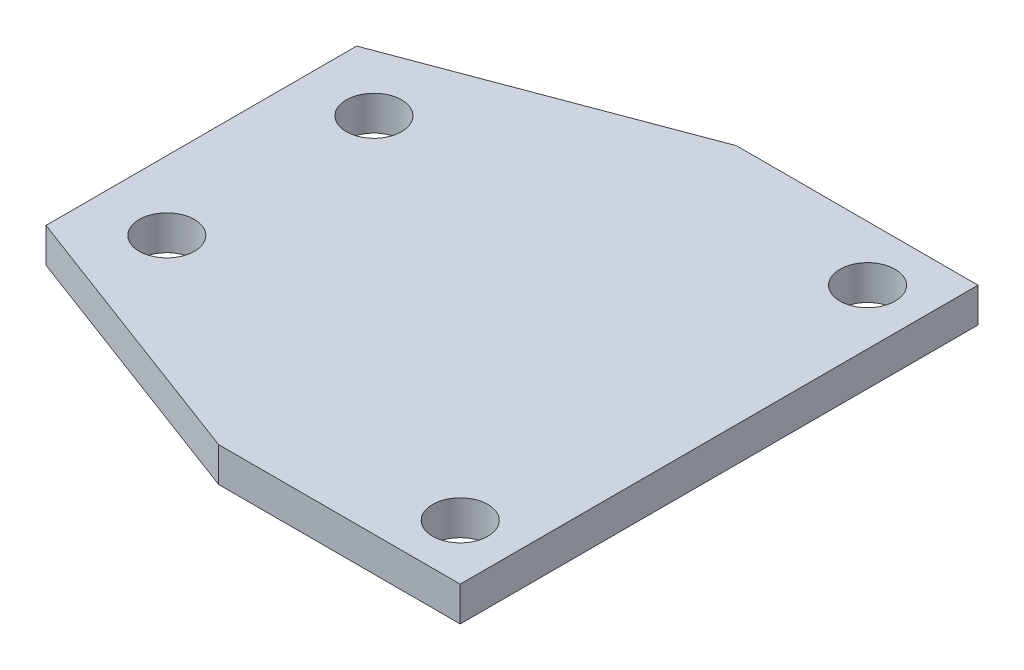
from build123d import *

# Parameters (mm, degrees)
SKETCH1_W           = 150
SKETCH1_H           = 150
BOSS_EXTRUDE1_DEPTH = 10
CHAMFER1_SIZE       = 30
CHAMFER1_SIZE2      = 80
CHAMFER2_SIZE       = 80
CHAMFER2_SIZE2      = 30
SKETCH2_R           = 8
CUT_EXTRUDE1_DEPTH  = 10


with BuildPart() as part:
    # Sketch1 → Boss-Extrude1 (new body)
    with BuildSketch(Plane(origin=(0, 0, 0), x_dir=(1, 0, 0), z_dir=(0, 1, 0))):
        with Locations((75, 75)):
            Rectangle(SKETCH1_W, SKETCH1_H)
    extrude(amount=BOSS_EXTRUDE1_DEPTH)

    # Chamfer1
    chamfer1_edges = [part.edges().sort_by_distance(p)[0] for p in [
        (0, 5, 0),
    ]]
    chamfer1_side = [part.faces().sort_by_distance(p)[0] for p in [
        (0, 5, -75),
    ]]
    chamfer(chamfer1_edges, length=CHAMFER1_SIZE, length2=CHAMFER1_SIZE2, reference=chamfer1_side[0])

    # Chamfer2
    chamfer2_edges = [part.edges().sort_by_distance(p)[0] for p in [
        (0, 5, -150),
    ]]
    chamfer2_side = [part.faces().sort_by_distance(p)[0] for p in [
        (75, 5, -150),
    ]]
    chamfer(chamfer2_edges, length=CHAMFER2_SIZE, length2=CHAMFER2_SIZE2, reference=chamfer2_side[0])

    # Sketch2 → Cut-Extrude1 (cut)
    with BuildSketch(Plane(origin=(0, 10, 0), x_dir=(1, 0, 0), z_dir=(0, 1, 0))):
        with Locations((134, 134)):
            Circle(SKETCH2_R)
        with Locations((134, 16)):
            Circle(SKETCH2_R)
        with Locations((20, 105)):
            Circle(SKETCH2_R)
        with Locations((20, 45)):
            Circle(SKETCH2_R)
    extrude(amount=-CUT_EXTRUDE1_DEPTH, mode=Mode.SUBTRACT)


solid = part.part
